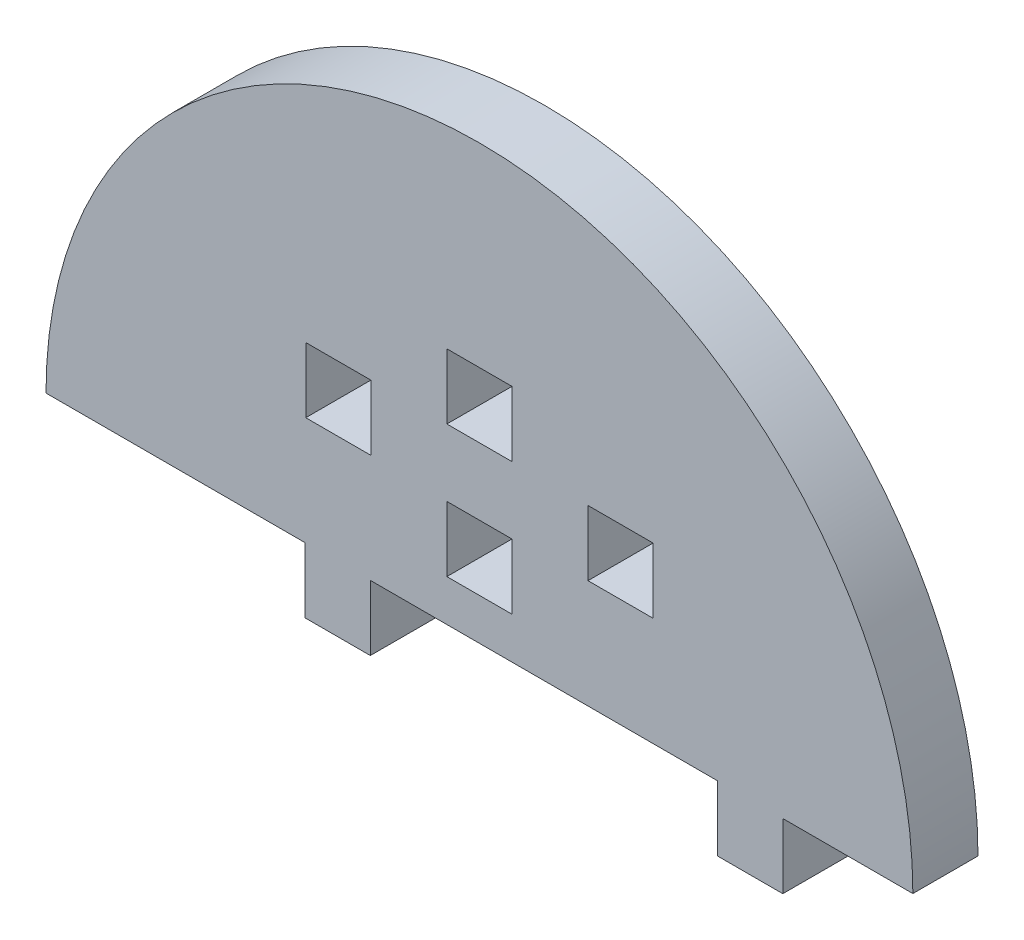
from build123d import *

# Parameters (mm, degrees)
MODEL_W             = 6
MODEL_H             = 6
BOSS_EXTRUDE1_DEPTH = 6


with BuildPart() as part:
    # Model → Boss-Extrude1 (new body)
    with BuildSketch(Plane.XY):
        with BuildLine():
            Line((3550.284318909, 1061.748947436), (3550.284318909, 1055.748947436))
            Line((3550.284318909, 1055.748947436), (3556.284318909, 1055.748947436))
            Line((3556.284318909, 1055.748947436), (3556.284318909, 1061.748947436))
            Line((3556.284318909, 1061.748947436), (3568.264255366, 1061.748947436))
            ThreePointArc((3568.264255366, 1061.748947436), (3528.335683937, 1101.677518865), (3488.407112509, 1061.748947436))
            Line((3488.407112509, 1061.748947436), (3512.284318909, 1061.748947436))
            Line((3512.284318909, 1061.748947436), (3512.284318909, 1055.748947436))
            Line((3512.284318909, 1055.748947436), (3518.284318909, 1055.748947436))
            Line((3518.284318909, 1055.748947436), (3518.284318909, 1061.748947436))
            Line((3518.284318909, 1061.748947436), (3550.284318909, 1061.748947436))
        make_face()
        with Locations((3541.335683937, 1074.748947436)):
            Rectangle(MODEL_W, MODEL_H, mode=Mode.SUBTRACT)
        with Locations((3515.335683937, 1074.748947436)):
            Rectangle(MODEL_W, MODEL_H, mode=Mode.SUBTRACT)
        with Locations((3528.335683937, 1080.748947436)):
            Rectangle(MODEL_W, MODEL_H, mode=Mode.SUBTRACT)
        with Locations((3528.335683937, 1068.57340627)):
            Rectangle(MODEL_W, MODEL_H, mode=Mode.SUBTRACT)
    extrude(amount=BOSS_EXTRUDE1_DEPTH)


solid = part.part
